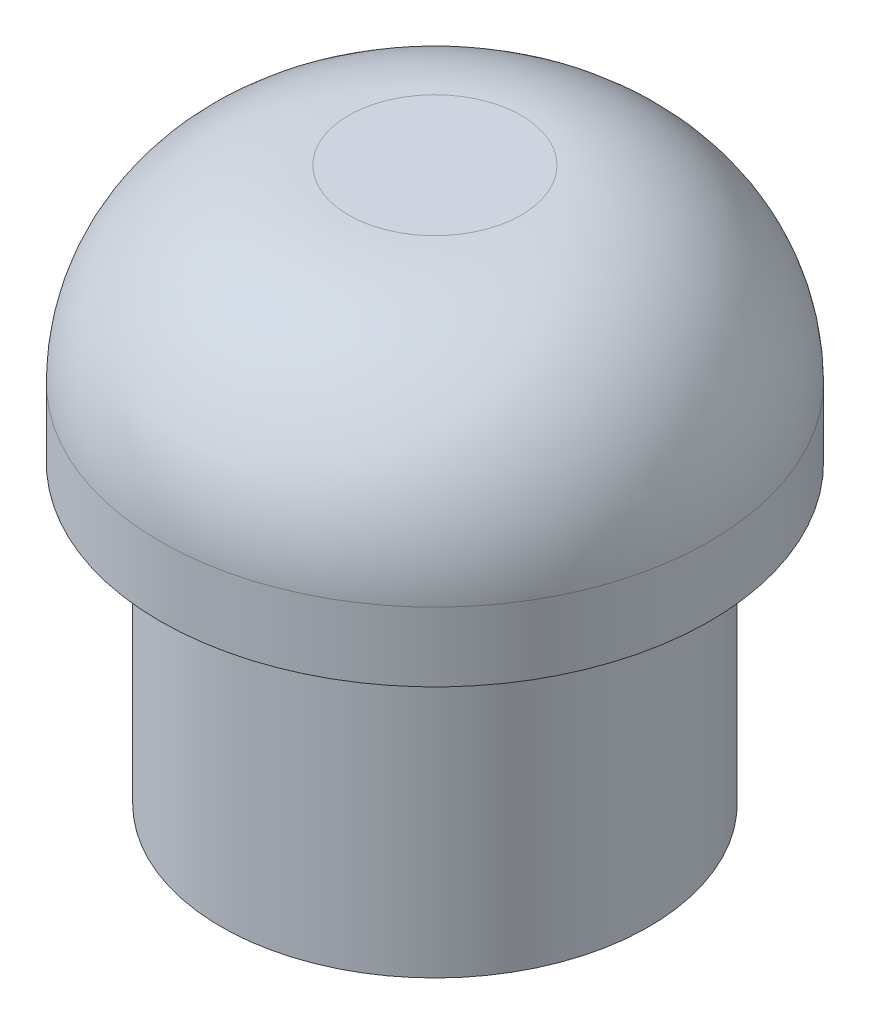
from build123d import *

# Parameters (mm, degrees)
SKETCH1_R           = 8.75
BOSS_EXTRUDE1_DEPTH = 8.2
FILLET1_R           = 6
BOSS_EXTRUDE2_DEPTH = 9.4


with BuildPart() as part:
    # Sketch1 → Boss-Extrude1 (new body)
    with BuildSketch(Plane(origin=(0, 0, 0), x_dir=(1, 0, 0), z_dir=(0, 1, 0))):
        Circle(SKETCH1_R)
    extrude(amount=BOSS_EXTRUDE1_DEPTH)

    # Fillet1
    fillet1_edges = [part.edges().sort_by_distance(p)[0] for p in [
        (-8.75, 8.2, 0),
    ]]
    fillet(fillet1_edges, radius=FILLET1_R)

    # Sketch2 → Boss-Extrude2 (add)
    with BuildSketch(Plane.XZ):
        with BuildLine():
            ThreePointArc((4.292019342, -5.283154258), (6.146066324, -2.925579889), (6.806845742, 0))
            ThreePointArc((6.806845742, 0), (1.4e-08, 6.806845742), (-6.806845742, 2.9e-08))
            ThreePointArc((-6.806845742, 2.9e-08), (-6.146066331, -2.925579876), (-4.292019342, -5.283154258))
            Line((-4.292019342, -5.283154258), (4.292019342, -5.283154258))
        make_face()
    extrude(amount=BOSS_EXTRUDE2_DEPTH)


solid = part.part
